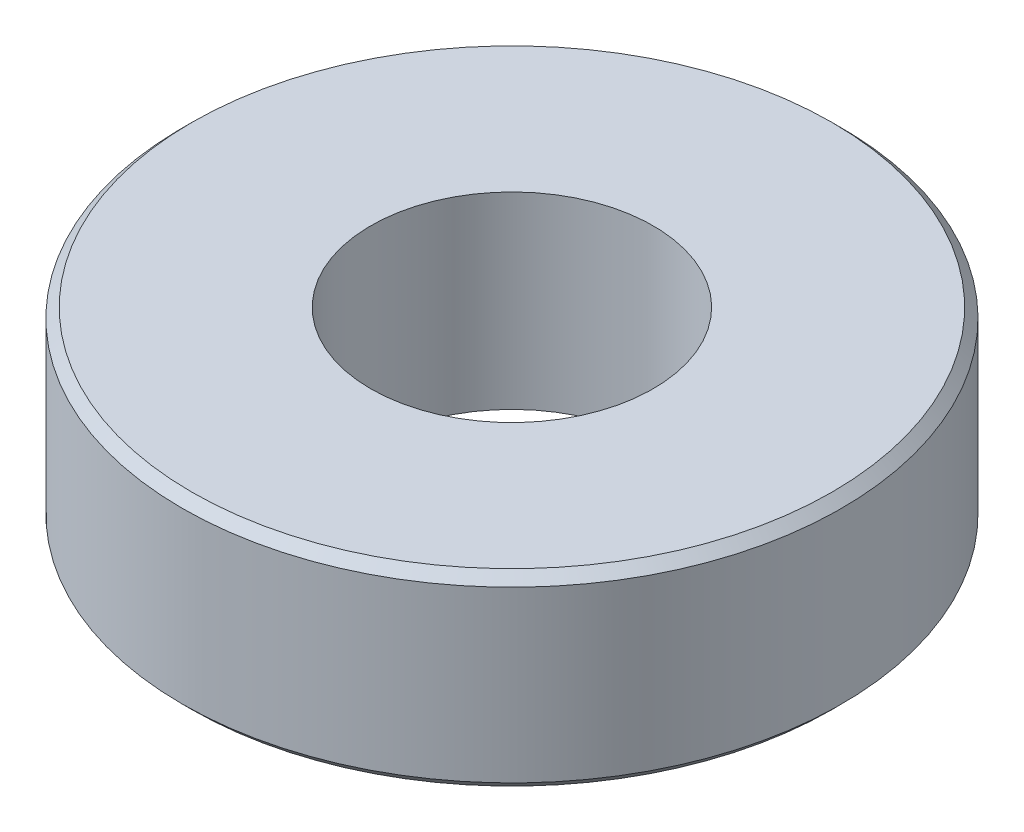
from build123d import *

# Parameters (mm, degrees)
SKETCH_1_R      = 7
SKETCH_1_R_2    = 3
EXTRUDE_1_DEPTH = 4
CHAMFER_1_SIZE  = 0.2


with BuildPart() as part:
    # 草图1 → 凸台-拉伸1 (new body)
    with BuildSketch(Plane(origin=(0, 0, 0), x_dir=(1, 0, 0), z_dir=(0, 1, 0))):
        Circle(SKETCH_1_R)
        Circle(SKETCH_1_R_2, mode=Mode.SUBTRACT)
    extrude(amount=EXTRUDE_1_DEPTH)

    # 倒角1
    chamfer_1_edges = [part.edges().sort_by_distance(p)[0] for p in [
        (-7, 0, 0),
        (-7, 4, 0),
    ]]
    chamfer(chamfer_1_edges, length=CHAMFER_1_SIZE)


solid = part.part
